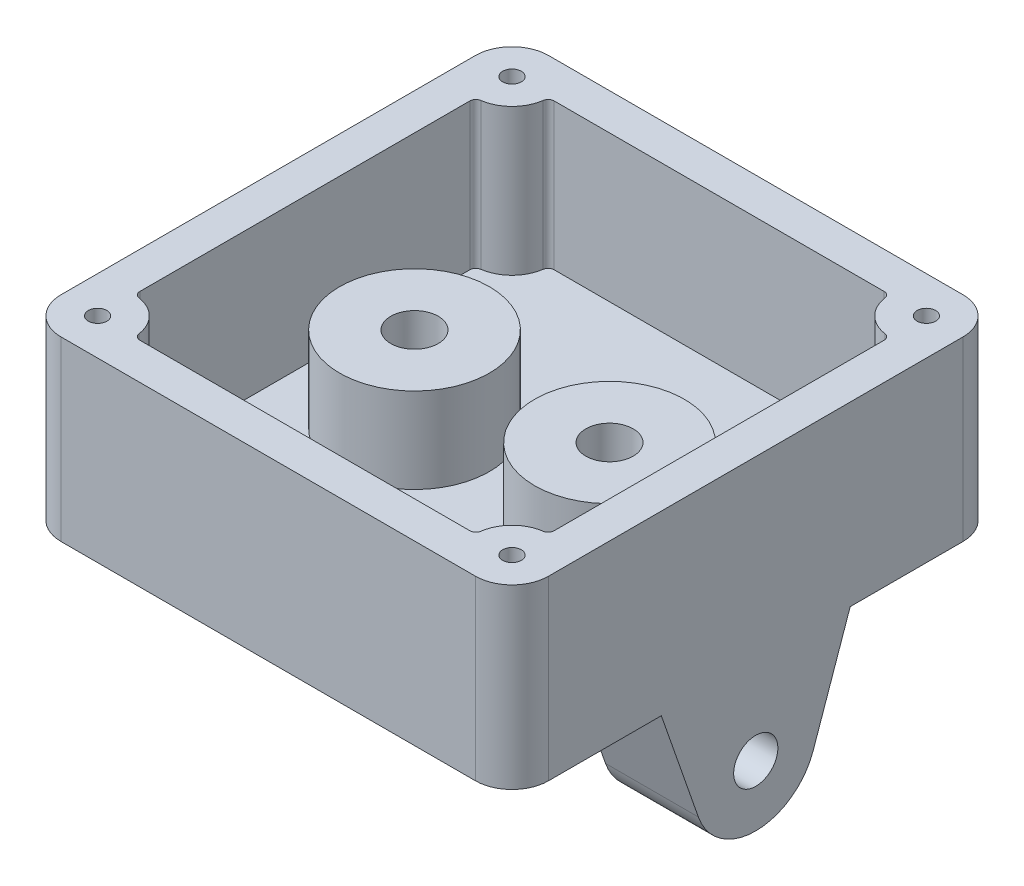
from build123d import *

# Parameters (mm, degrees)
SKETCH1_W           = 40
SKETCH1_H           = 40
BOSS_EXTRUDE1_DEPTH = 2.54
SKETCH2_W           = 40
SKETCH2_H           = 40
BOSS_EXTRUDE2_DEPTH = 12
SKETCH4_R           = 1.813765306
BOSS_EXTRUDE4_DEPTH = 7.62
SKETCH9_R           = 6.145
SKETCH9_R_2         = 1.945
BOSS_EXTRUDE5_DEPTH = 7
FILLET1_R           = 3
SKETCH10_R          = 0.761723834
CUT_EXTRUDE1_DEPTH  = 8


with BuildPart() as part:
    # Sketch1 → Boss-Extrude1 (new body)
    with BuildSketch(Plane(origin=(0, 0, 0), x_dir=(1, 0, 0), z_dir=(0, 1, 0))):
        Rectangle(SKETCH1_W, SKETCH1_H)
    extrude(amount=BOSS_EXTRUDE1_DEPTH)

    # Sketch2 → Boss-Extrude2 (add)
    with BuildSketch(Plane(origin=(0, 2.54, 0), x_dir=(1, 0, 0), z_dir=(0, 1, 0))):
        Rectangle(SKETCH2_W, SKETCH2_H)
        with BuildLine():
            Line((-17, 13.535898385), (-17, -13.535898385))
            ThreePointArc((-17, -13.535898385), (-16.877964473, -13.86322522), (-16.571428571, -14.030770044))
            ThreePointArc((-16.571428571, -14.030770044), (-14.878679656, -14.878679656), (-14.030770044, -16.571428571))
            ThreePointArc((-14.030770044, -16.571428571), (-13.86322522, -16.877964473), (-13.535898385, -17))
            Line((-13.535898385, -17), (13.535898385, -17))
            ThreePointArc((13.535898385, -17), (13.86322522, -16.877964473), (14.030770044, -16.571428571))
            ThreePointArc((14.030770044, -16.571428571), (14.878679656, -14.878679656), (16.571428571, -14.030770044))
            ThreePointArc((16.571428571, -14.030770044), (16.877964473, -13.86322522), (17, -13.535898385))
            Line((17, -13.535898385), (17, 13.535898385))
            ThreePointArc((17, 13.535898385), (16.877964473, 13.86322522), (16.571428571, 14.030770044))
            ThreePointArc((16.571428571, 14.030770044), (14.878679656, 14.878679656), (14.030770044, 16.571428571))
            ThreePointArc((14.030770044, 16.571428571), (13.86322522, 16.877964473), (13.535898385, 17))
            Line((13.535898385, 17), (-13.535898385, 17))
            ThreePointArc((-13.535898385, 17), (-13.86322522, 16.877964473), (-14.030770044, 16.571428571))
            ThreePointArc((-14.030770044, 16.571428571), (-14.878679656, 14.878679656), (-16.571428571, 14.030770044))
            ThreePointArc((-16.571428571, 14.030770044), (-16.877964473, 13.86322522), (-17, 13.535898385))
        make_face(mode=Mode.SUBTRACT)
    extrude(amount=BOSS_EXTRUDE2_DEPTH)

    # Sketch4 → Boss-Extrude4 (add)
    with BuildSketch(Plane.ZY.offset(20)):
        with BuildLine():
            Line((7.748459825, 0), (4.708955343, -8.719310622))
            ThreePointArc((4.708955343, -8.719310622), (0, -12.064660663), (-4.708955343, -8.719310622))
            Line((-4.708955343, -8.719310622), (-7.748459825, 0))
            Line((-7.748459825, 0), (7.748459825, 0))
        make_face()
        with Locations((0, -7.077794281)):
            Circle(SKETCH4_R, mode=Mode.SUBTRACT)
    boss_extrude4 = extrude(amount=-BOSS_EXTRUDE4_DEPTH)

    # Mirror1: Boss-Extrude4 across plane
    add(boss_extrude4.mirror(Plane(origin=(0, 0, 0), x_dir=(0, 0, 1), z_dir=(1, 0, 0))))

    # Sketch9 → Boss-Extrude5 (add)
    with BuildSketch(Plane(origin=(0, 2.54, 0), x_dir=(1, 0, 0), z_dir=(0, 1, 0))):
        with Locations((8, 0)):
            Circle(SKETCH9_R)
        with Locations((8, 0)):
            Circle(SKETCH9_R_2, mode=Mode.SUBTRACT)
        with Locations((-8, 0)):
            Circle(SKETCH9_R)
        with Locations((-8, 0)):
            Circle(SKETCH9_R_2, mode=Mode.SUBTRACT)
    extrude(amount=BOSS_EXTRUDE5_DEPTH)

    # Fillet1
    fillet1_edges = [part.edges().sort_by_distance(p)[0] for p in [
        (20, 7.27, 20),
        (-20, 7.27, 20),
        (-20, 7.27, -20),
        (20, 7.27, -20),
    ]]
    fillet(fillet1_edges, radius=FILLET1_R)

    # Sketch10 → Cut-Extrude1 (cut)
    with BuildSketch(Plane(origin=(0, 14.54, 0), x_dir=(1, 0, 0), z_dir=(0, 1, 0))):
        with Locations((-17, 17)):
            Circle(SKETCH10_R)
        with Locations((17, 17)):
            Circle(SKETCH10_R)
        with Locations((-17, -17)):
            Circle(SKETCH10_R)
        with Locations((17, -17)):
            Circle(SKETCH10_R)
    extrude(amount=-CUT_EXTRUDE1_DEPTH, mode=Mode.SUBTRACT)


solid = part.part
